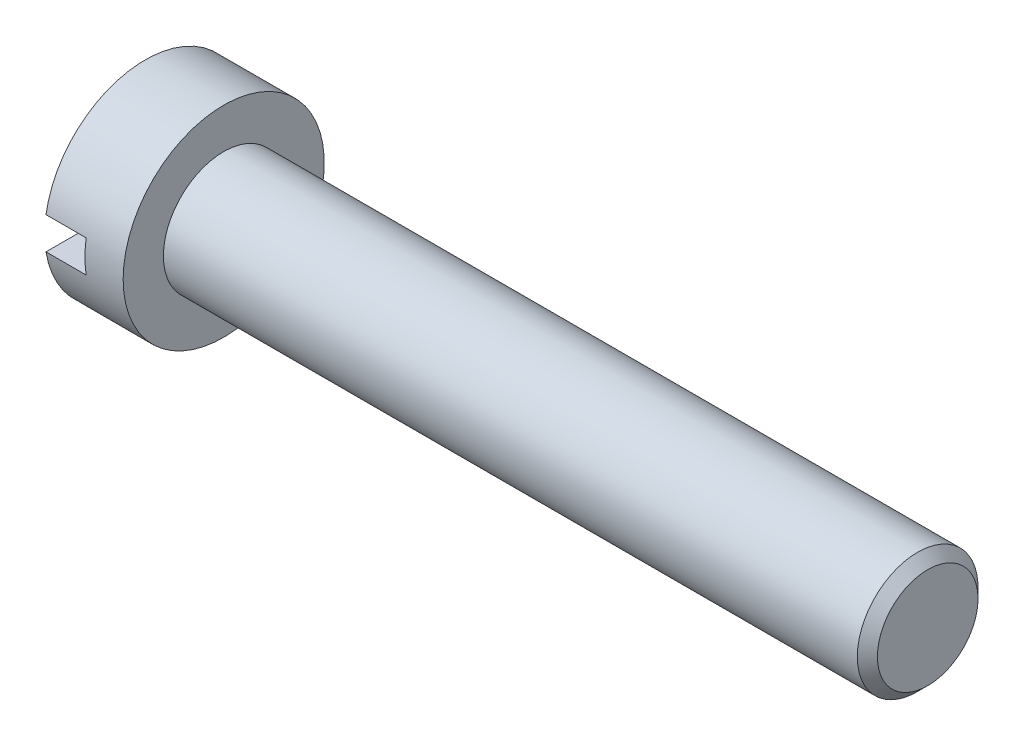
from build123d import *

# Parameters (mm, degrees)
ESQUISSE2_W             = 12
ESQUISSE2_H             = 1.6
ENL_V_MAT_EXTRU_1_DEPTH = 2


with BuildPart() as part:
    # Esquisse1 → Révolution1 (revolve)
    with BuildSketch(Plane.XY, mode=Mode.PRIVATE) as r_volution1_sk:
        Polygon((0, 3), (0, 5), (-3.9, 5), (-3.9, 0), (35, 0), (35, 2.5), (34.5, 3), align=None)
    revolve(r_volution1_sk.sketch.rotate(Axis((-3.9, 0, 0), (1, 0, 0)), 90), axis=Axis((-3.9, 0, 0), (1, 0, 0)))  # turned: the seam where the file's is

    # Esquisse2 → Enlèv. mat.-Extru.1 (cut)
    with BuildSketch(Plane.ZY.offset(3.9)):
        Rectangle(ESQUISSE2_W, ESQUISSE2_H)
    extrude(amount=-ENL_V_MAT_EXTRU_1_DEPTH, mode=Mode.SUBTRACT)


solid = part.part
